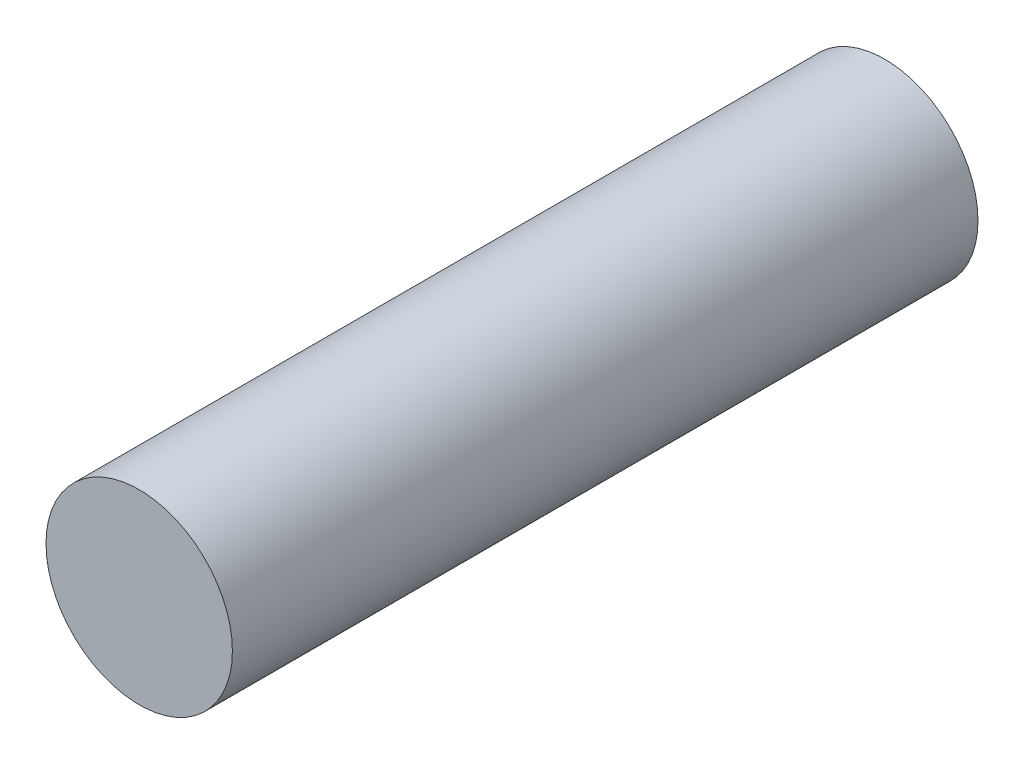
from build123d import *

# Parameters (mm, degrees)
SKETCH1_R           = 1.25
BOSS_EXTRUDE1_DEPTH = 10


with BuildPart() as part:
    # Sketch1 → Boss-Extrude1 (new body)
    with BuildSketch(Plane.XY):
        Circle(SKETCH1_R)
    extrude(amount=BOSS_EXTRUDE1_DEPTH)


solid = part.part
